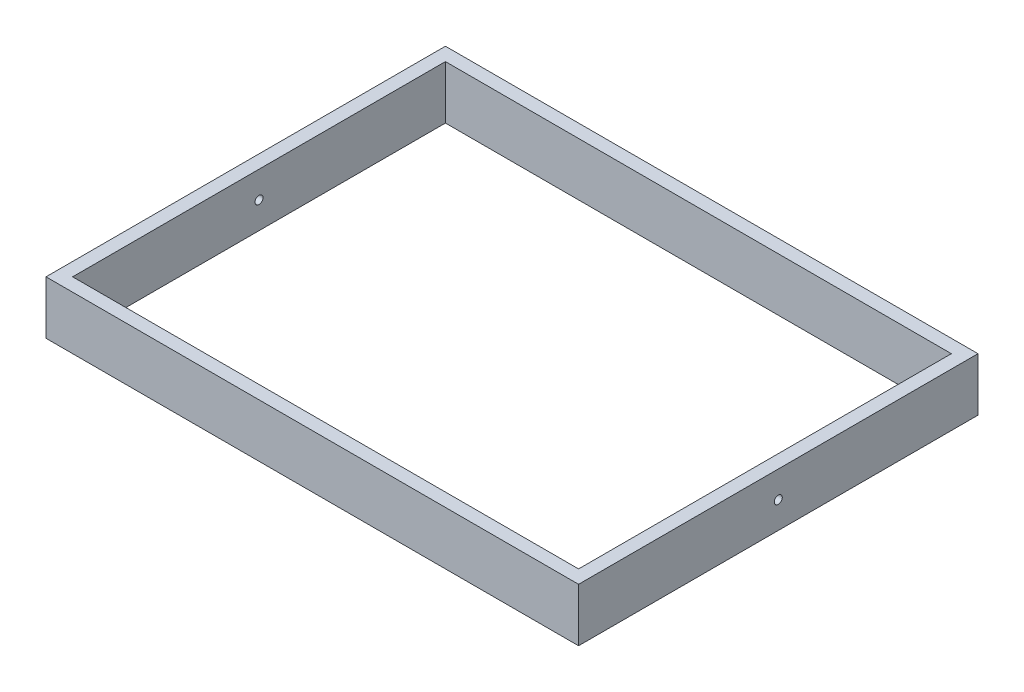
from build123d import *

# Parameters (mm, degrees)
SKETCH1_W           = 400
SKETCH1_H           = 300
SKETCH1_W_2         = 380
SKETCH1_H_2         = 280
BOSS_EXTRUDE1_DEPTH = 40
SKETCH4_R           = 3
BOSS_EXTRUDE4_DEPTH = 10
SKETCH2_R           = 3
CUT_EXTRUDE1_DEPTH  = 400


with BuildPart() as part:
    # Sketch1 → Boss-Extrude1 (new body)
    with BuildSketch(Plane(origin=(0, 0, 0), x_dir=(1, 0, 0), z_dir=(0, 1, 0))):
        Rectangle(SKETCH1_W, SKETCH1_H)
        Rectangle(SKETCH1_W_2, SKETCH1_H_2, mode=Mode.SUBTRACT)
    extrude(amount=BOSS_EXTRUDE1_DEPTH)

    # Sketch4 → Boss-Extrude4 (add)
    with BuildSketch(Plane.ZY.offset(200)):
        with Locations((110, 20)):
            Circle(SKETCH4_R)
    extrude(amount=BOSS_EXTRUDE4_DEPTH)

    # Sketch2 → Cut-Extrude1 (cut)
    with BuildSketch(Plane(origin=(200, 0, 0), x_dir=(0, 0, -1), z_dir=(1, 0, 0))):
        with Locations((0, 20)):
            Circle(SKETCH2_R)
    extrude(amount=-CUT_EXTRUDE1_DEPTH, mode=Mode.SUBTRACT)


solid = part.part
